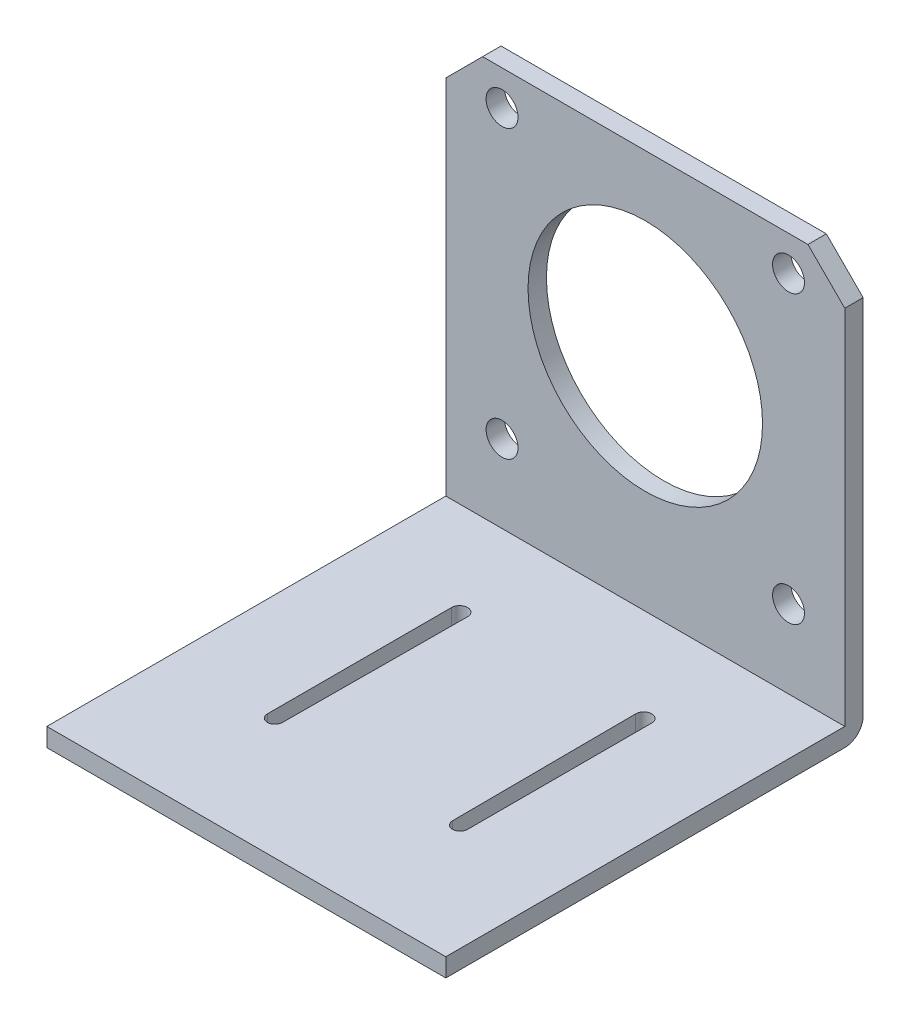
from build123d import *

# Parameters (mm, degrees)
EXTRUDE_1_DEPTH      = 32.5
EXTRUDE_1_DEPTH_BACK = 32.5
FILLET_2_R           = 3
SKETCH_2_R           = 19.1
SKETCH_2_R_2         = 2.6
CUT_EXTRUDE_1_DEPTH  = 13.125
CUT_EXTRUDE_2_DEPTH  = 10


with BuildPart() as part:
    # Эскиз1 → Бобышка-Вытянуть1 (new, two sides: drawn at the far end of the back side and taken through both)
    with BuildSketch(Plane(origin=(0, 0, 0), x_dir=(0, 0, -1), z_dir=(1, 0, 0)).offset(-EXTRUDE_1_DEPTH_BACK)):
        Polygon((7, 65), (7, -3), (-61, -3), (-61, 0), (4, 0), (4, 65), align=None)
    extrude(amount=EXTRUDE_1_DEPTH + EXTRUDE_1_DEPTH_BACK)

    # Скругление2
    fillet_2_edges = [part.edges().sort_by_distance(p)[0] for p in [
        (0, -3, -7),
    ]]
    fillet(fillet_2_edges, radius=FILLET_2_R)

    # Эскиз2 → Вырез-Вытянуть1 (cut)
    with BuildSketch(Plane(origin=(0, 0, -7), x_dir=(-1, 0, 0), z_dir=(0, 0, -1))):
        with Locations((0, 36)):
            Circle(SKETCH_2_R)
        with Locations((-23.334523779, 59.334523779)):
            Circle(SKETCH_2_R_2)
        with Locations((23.334523779, 59.334523779)):
            Circle(SKETCH_2_R_2)
        with Locations((23.334523779, 12.665476221)):
            Circle(SKETCH_2_R_2)
        with Locations((-23.334523779, 12.665476221)):
            Circle(SKETCH_2_R_2)
        Polygon((-26.5, 65), (-32.5, 59), (-32.5, 65), align=None)
        Polygon((32.5, 59), (32.5, 65), (26.5, 65), align=None)
    extrude(amount=-CUT_EXTRUDE_1_DEPTH, mode=Mode.SUBTRACT)

    # Эскиз3 → Вырез-Вытянуть2 (cut)
    with BuildSketch(Plane(origin=(0, 0, 0), x_dir=(1, 0, 0), z_dir=(0, 1, 0))):
        with BuildLine():
            ThreePointArc((-13.695464845, -11.253573908), (-15, -9.949038753), (-16.304535155, -11.253573908))
            Line((-16.304535155, -11.253573908), (-16.304535155, -41.253573908))
            ThreePointArc((-16.304535155, -41.253573908), (-15.08357618, -42.474532883), (-13.862617205, -41.253573908))
            Line((-13.862617205, -41.253573908), (-13.695464845, -11.253573908))
        make_face()
        with BuildLine():
            Line((16.304535155, -41.253573908), (16.304535155, -11.253573908))
            ThreePointArc((16.304535155, -11.253573908), (15, -9.949038753), (13.695464845, -11.253573908))
            Line((13.695464845, -11.253573908), (13.862617205, -41.253573908))
            ThreePointArc((13.862617205, -41.253573908), (15.08357618, -42.474532883), (16.304535155, -41.253573908))
        make_face()
    extrude(amount=-CUT_EXTRUDE_2_DEPTH, mode=Mode.SUBTRACT)


solid = part.part
